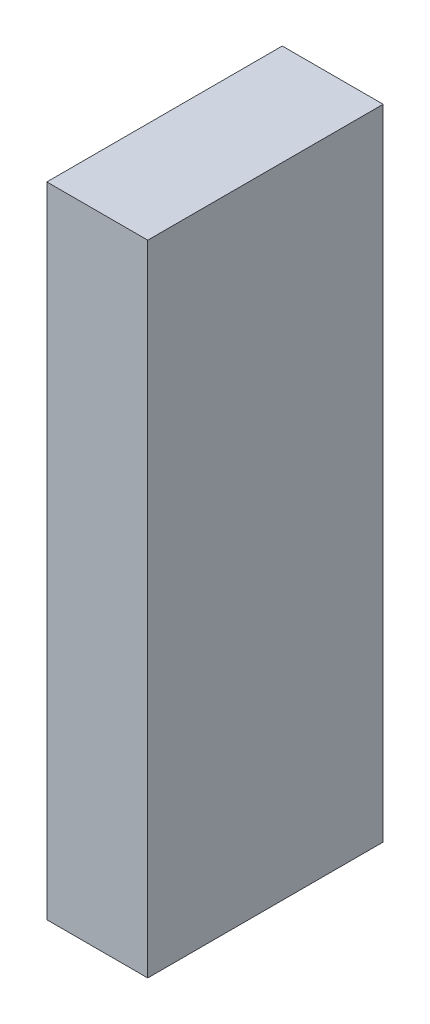
from build123d import *

# Parameters (mm, degrees)
SKETCH1_W           = 38.1
SKETCH1_H           = 88.9
BOSS_EXTRUDE1_DEPTH = 120.65


with BuildPart() as part:
    # Sketch1 → Boss-Extrude1 (new body, symmetric)
    with BuildSketch(Plane(origin=(0, 0, 0), x_dir=(1, 0, 0), z_dir=(0, 1, 0))):
        Rectangle(SKETCH1_W, SKETCH1_H)
    extrude(amount=BOSS_EXTRUDE1_DEPTH, both=True)


solid = part.part
